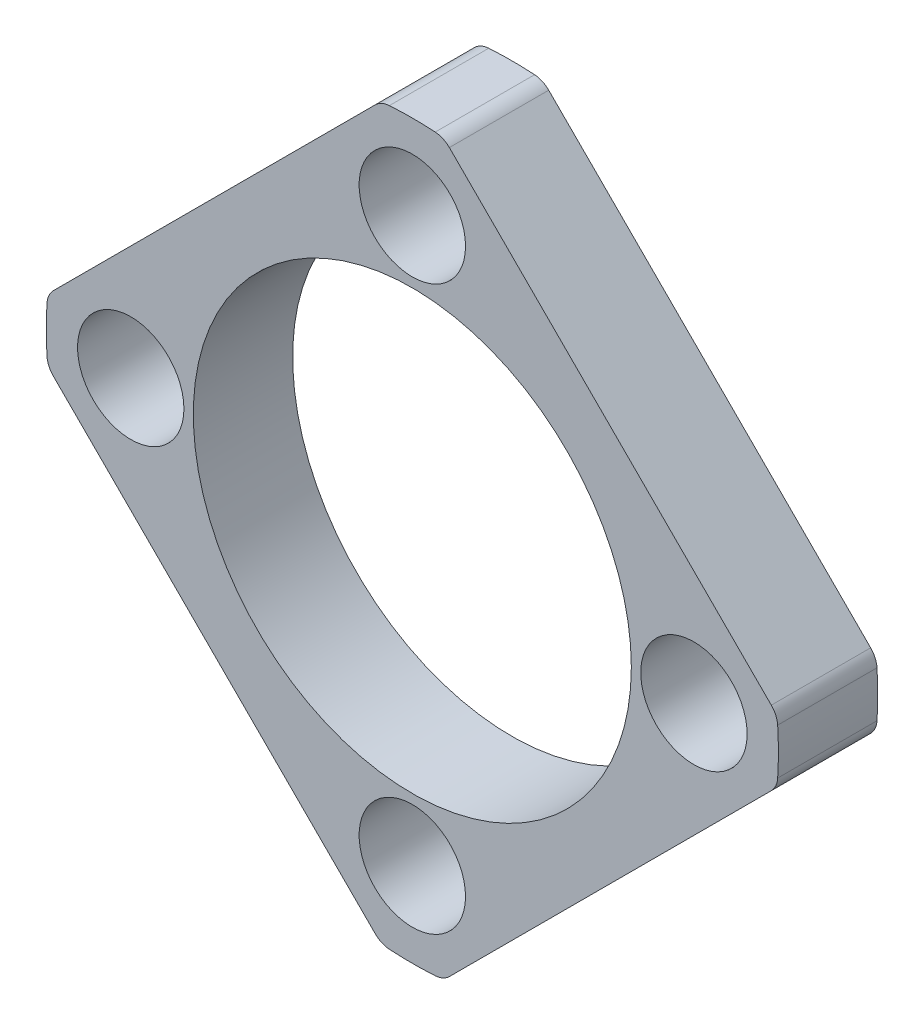
from build123d import *

# Parameters (mm, degrees)
SKETCH1_R           = 1.7
SKETCH1_R_2         = 7
BOSS_EXTRUDE1_DEPTH = 3.175


with BuildPart() as part:
    # Sketch1 → Boss-Extrude1 (new body)
    with BuildSketch(Plane.XY):
        with BuildLine():
            Line((-1.183826785, 11.473384598), (-11.473384598, 1.183826785))
            ThreePointArc((-11.473384598, 1.183826785), (-11.616416331, 0.976858517), (-11.677035933, 0.732688077))
            ThreePointArc((-11.677035933, 0.732688077), (-11.7, 0), (-11.677035933, -0.732688077))
            ThreePointArc((-11.677035933, -0.732688077), (-11.616416331, -0.976858517), (-11.473384598, -1.183826785))
            Line((-11.473384598, -1.183826785), (-1.183826785, -11.473384598))
            ThreePointArc((-1.183826785, -11.473384598), (-0.976858517, -11.616416331), (-0.732688077, -11.677035933))
            ThreePointArc((-0.732688077, -11.677035933), (0, -11.7), (0.732688077, -11.677035933))
            ThreePointArc((0.732688077, -11.677035933), (0.976858517, -11.616416331), (1.183826785, -11.473384598))
            Line((1.183826785, -11.473384598), (11.473384598, -1.183826785))
            ThreePointArc((11.473384598, -1.183826785), (11.616416331, -0.976858517), (11.677035933, -0.732688077))
            ThreePointArc((11.677035933, -0.732688077), (11.7, 0), (11.677035933, 0.732688077))
            ThreePointArc((11.677035933, 0.732688077), (11.616416331, 0.976858517), (11.473384598, 1.183826785))
            Line((11.473384598, 1.183826785), (1.183826785, 11.473384598))
            ThreePointArc((1.183826785, 11.473384598), (0.976858517, 11.616416331), (0.732688077, 11.677035933))
            ThreePointArc((0.732688077, 11.677035933), (0, 11.7), (-0.732688077, 11.677035933))
            ThreePointArc((-0.732688077, 11.677035933), (-0.976858517, 11.616416331), (-1.183826785, 11.473384598))
        make_face()
        with Locations((0, -9)):
            Circle(SKETCH1_R, mode=Mode.SUBTRACT)
        with Locations((-9, 0)):
            Circle(SKETCH1_R, mode=Mode.SUBTRACT)
        with Locations((0, 9)):
            Circle(SKETCH1_R, mode=Mode.SUBTRACT)
        with Locations((9, 0)):
            Circle(SKETCH1_R, mode=Mode.SUBTRACT)
        Circle(SKETCH1_R_2, mode=Mode.SUBTRACT)
    extrude(amount=BOSS_EXTRUDE1_DEPTH)


solid = part.part
